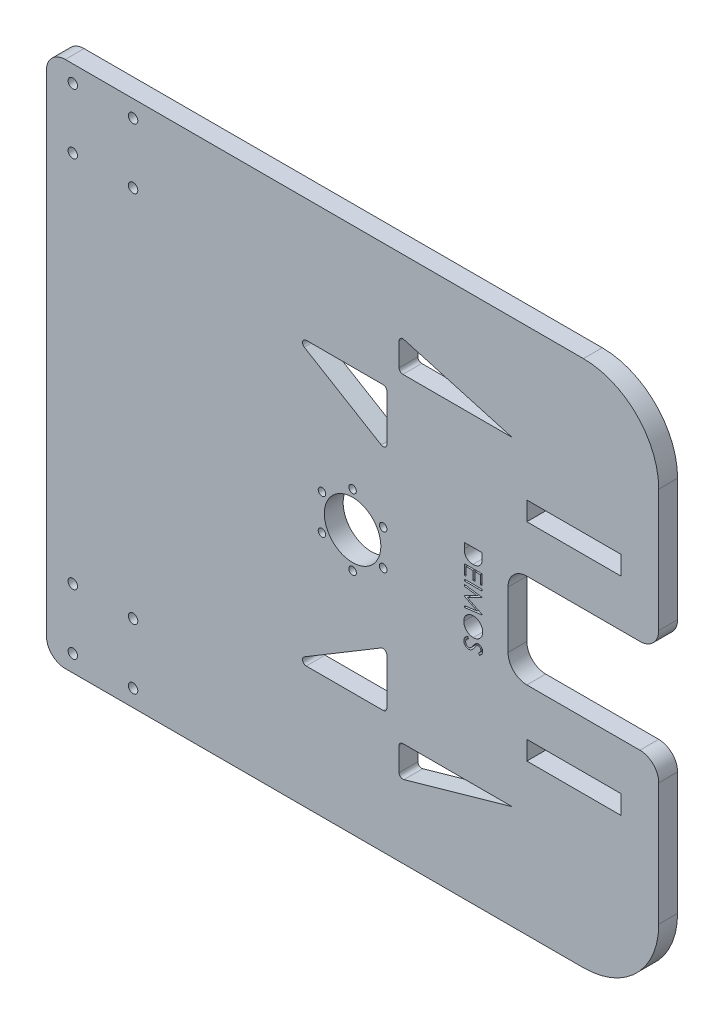
from build123d import *

# Parameters (mm, degrees)
SKETCH1_W           = 325
SKETCH1_H           = 280
SKETCH1_W_2         = 50
SKETCH1_H_2         = 10
SKETCH1_R           = 2
SKETCH1_R_2         = 15
BOSS_EXTRUDE1_DEPTH = 10
FILLET1_R           = 10
FILLET2_R           = 40
SKETCH4_W           = 80
SKETCH4_H           = 50
CUT_EXTRUDE5_DEPTH  = 10
FILLET4_R           = 10
FILLET5_R           = 2
SKETCH8_W           = 9.525
SKETCH8_H           = 0.854807693
CUT_EXTRUDE7_DEPTH  = 34
SKETCH9_R           = 2.5
CUT_EXTRUDE8_DEPTH  = 10


with BuildPart() as part:
    # Sketch1 → Boss-Extrude1 (new body)
    with BuildSketch(Plane.XY):
        with Locations((141.153836076, 0)):
            Rectangle(SKETCH1_W, SKETCH1_H)
        with Locations((258.653836076, -55)):
            Rectangle(SKETCH1_W_2, SKETCH1_H_2, mode=Mode.SUBTRACT)
        with Locations((258.653836076, 55)):
            Rectangle(SKETCH1_W_2, SKETCH1_H_2, mode=Mode.SUBTRACT)
        with Locations((157.391812397, 9.375)):
            Circle(SKETCH1_R, mode=Mode.SUBTRACT)
        with Locations((141.153836076, 18.75)):
            Circle(SKETCH1_R, mode=Mode.SUBTRACT)
        with Locations((124.915859755, -9.375)):
            Circle(SKETCH1_R, mode=Mode.SUBTRACT)
        with Locations((141.153836076, -18.75)):
            Circle(SKETCH1_R, mode=Mode.SUBTRACT)
        with Locations((157.391812397, -9.375)):
            Circle(SKETCH1_R, mode=Mode.SUBTRACT)
        with Locations((124.915859755, 9.375)):
            Circle(SKETCH1_R, mode=Mode.SUBTRACT)
        with Locations((141.153836076, 0)):
            Circle(SKETCH1_R_2, mode=Mode.SUBTRACT)
    extrude(amount=BOSS_EXTRUDE1_DEPTH)

    # Fillet1
    fillet1_edges = [part.edges().sort_by_distance(p)[0] for p in [
        (-21.346163924, -140, 5),
        (-21.346163924, 140, 5),
    ]]
    fillet(fillet1_edges, radius=FILLET1_R)

    # Fillet2
    fillet2_edges = [part.edges().sort_by_distance(p)[0] for p in [
        (303.653836076, 140, 5),
        (303.653836076, -140, 5),
    ]]
    fillet(fillet2_edges, radius=FILLET2_R)

    # Sketch4 → Cut-Extrude5 (cut)
    with BuildSketch(Plane.XY):
        with Locations((263.653836076, 0)):
            Rectangle(SKETCH4_W, SKETCH4_H)
        Polygon((109.344996748, -74.859442644), (159.344996748, -44.859442644), (159.344996748, -74.859442644), align=None)
        Polygon((165.847822117, -84.859442644), (225.847822117, -84.859442644), (165.847822117, -101.859442644), align=None)
        Polygon((159.344996748, 44.859442644), (159.344996748, 74.859442644), (109.344996748, 74.859442644), align=None)
        Polygon((225.847822117, 84.859442644), (165.847822117, 101.859442644), (165.847822117, 84.859442644), align=None)
    extrude(amount=CUT_EXTRUDE5_DEPTH, mode=Mode.SUBTRACT)

    # Fillet4
    fillet4_edges = [part.edges().sort_by_distance(p)[0] for p in [
        (303.653836076, 25, 5),
        (223.653836076, 25, 5),
        (223.653836076, -25, 5),
        (303.653836076, -25, 5),
    ]]
    fillet(fillet4_edges, radius=FILLET4_R)

    # Fillet5
    fillet5_edges = [part.edges().sort_by_distance(p)[0] for p in [
        (165.847822117, 84.859442644, 5),
        (165.847822117, 101.859442644, 5),
        (109.344996748, 74.859442644, 5),
        (159.344996748, 44.859442644, 5),
        (159.344996748, 74.859442644, 5),
        (159.344996748, -74.859442644, 5),
        (159.344996748, -44.859442644, 5),
        (109.344996748, -74.859442644, 5),
        (165.847822117, -101.859442644, 5),
        (165.847822117, -84.859442644, 5),
    ]]
    fillet(fillet5_edges, radius=FILLET5_R)

    # Sketch8 → Cut-Extrude7 (cut)
    with BuildSketch(Plane.XY.offset(10)):
        with BuildLine():
            Line((200.440471707, 23.934615385), (209.965471707, 23.934615385))
            Line((209.965471707, 23.934615385), (209.965471707, 22.011298077))
            add(Edge.make_bspline(
                [(209.965471707, 22.011298077), (209.964270566, 21.844014268), (209.961949968, 21.520822821), (209.947152078, 21.053796461), (209.921238906, 20.622294118), (209.882765221, 20.226560835), (209.836586017, 19.865960835), (209.777857599, 19.541071661), (209.708789002, 19.251366805), (209.649879683, 19.073196747), (209.622022187, 18.988942308)],
                knots=[0, 0, 0, 0, 0.000501851, 0.000969573, 0.001401619, 0.001798425, 0.002162189, 0.002491907, 0.002788546, 0.00305467, 0.00305467, 0.00305467, 0.00305467], degree=3))
            add(Edge.make_bspline(
                [(209.622022187, 18.988942308), (209.580028577, 18.878738837), (209.496993632, 18.660830945), (209.340358953, 18.350567689), (209.162883606, 18.05849316), (208.964348832, 17.783018556), (208.739076507, 17.530519725), (208.496845936, 17.290816903), (208.227758902, 17.074670535), (207.94095172, 16.873406548), (207.633514858, 16.697297269), (207.311687884, 16.54198934), (206.976072973, 16.409383485), (206.624227345, 16.305914399), (206.259528694, 16.22043131), (205.879216258, 16.163074194), (205.485507163, 16.124974184), (205.218328935, 16.121164022), (205.082764375, 16.119230769)],
                knots=[0, 0, 0, 0, 0.000353608, 0.000699197, 0.00104083, 0.00137821, 0.001716199, 0.002054872, 0.002399359, 0.002750285, 0.003105049, 0.003460915, 0.003821618, 0.004186221, 0.004560204, 0.004944486, 0.005339213, 0.00574579, 0.00574579, 0.00574579, 0.00574579], degree=3))
            add(Edge.make_bspline(
                [(205.082764375, 16.119230769), (204.965032402, 16.120943613), (204.733029254, 16.12431895), (204.391100832, 16.154590077), (204.059342581, 16.19867311), (203.739211546, 16.266610307), (203.42855118, 16.350088741), (203.12883677, 16.453126869), (202.839848629, 16.575237028), (202.56394077, 16.716909335), (202.301569629, 16.871821715), (202.057250154, 17.041674075), (201.82633571, 17.216719714), (201.619241743, 17.410455773), (201.424123862, 17.609531684), (201.251524644, 17.824504057), (201.093925803, 18.048369221), (200.952477694, 18.285439171), (200.829755793, 18.541396111), (200.724622122, 18.819733515), (200.638055098, 19.121942075), (200.565714706, 19.447558579), (200.50836302, 19.797221059), (200.469916507, 20.171250253), (200.443919613, 20.569077959), (200.441643325, 20.842252914), (200.440471707, 20.982857572)],
                knots=[0, 0, 0, 0, 0.000353119, 0.000695857, 0.001029112, 0.001356547, 0.00167685, 0.001993639, 0.002306565, 0.002617179, 0.002923468, 0.003219849, 0.003509528, 0.003791772, 0.004069759, 0.004345107, 0.004617718, 0.00489063, 0.005172254, 0.005468156, 0.005782145, 0.006114519, 0.006468353, 0.006844472, 0.007242122, 0.00766387, 0.00766387, 0.00766387, 0.00766387], degree=3))
            Line((200.440471707, 20.982857572), (200.440471707, 23.934615385))
        make_face()
        Polygon((209.965471707, 14.165384615), (209.965471707, 8.792307692), (208.98854863, 8.792307692), (208.98854863, 13.310576923), (206.057779399, 13.310576923), (206.057779399, 8.792307692), (205.080856322, 8.792307692), (205.080856322, 13.310576923), (201.417394783, 13.310576923), (201.417394783, 8.792307692), (200.440471707, 8.792307692), (200.440471707, 14.165384615), align=None)
        with Locations((205.202971707, 6.655288462)):
            Rectangle(SKETCH8_W, SKETCH8_H)
        Polygon((200.440471707, 4.640384615), (209.965471707, 3.382977764), (209.965471707, 3.26086238), (202.150087091, -0.671634615), (209.965471707, -4.592683293), (209.965471707, -4.714798678), (200.440471707, -5.983653846), (200.440471707, -5.128846154), (207.288473509, -4.212980769), (200.440471707, -0.776577524), (200.440471707, -0.58195613), (207.309462091, 2.869711538), (200.440471707, 3.779852764), align=None)
        with BuildLine():
            add(Edge.make_bspline(
                [(210.209702476, -12.394711538), (210.205235266, -12.571082134), (210.196461298, -12.917488535), (210.129299459, -13.426600011), (210.013104886, -13.912631959), (209.858364071, -14.379554575), (209.651903225, -14.821742714), (209.402495682, -15.242674716), (209.106594281, -15.641160444), (208.769164109, -16.013547296), (208.400688035, -16.353065594), (208.006324048, -16.649700392), (207.591472349, -16.900502873), (207.154689363, -17.106068081), (206.697897528, -17.267481758), (206.218499608, -17.378829993), (205.719645562, -17.449965839), (205.379393603, -17.458281542), (205.206787812, -17.4625)],
                knots=[0, 0, 0, 0, 0.000529026, 0.001039051, 0.001537035, 0.002026379, 0.002512127, 0.002998067, 0.00349188, 0.003998478, 0.00450354, 0.004992765, 0.00547641, 0.005955244, 0.006438614, 0.006926874, 0.007429591, 0.00794718, 0.00794718, 0.00794718, 0.00794718], degree=3))
            add(Edge.make_bspline(
                [(205.206787812, -17.4625), (205.035453471, -17.458282168), (204.697733636, -17.449968331), (204.202045381, -17.37874903), (203.725540779, -17.267069316), (203.269061561, -17.107565396), (202.831954548, -16.902987724), (202.416340309, -16.650490184), (202.019245707, -16.3558193), (201.648980849, -16.017474517), (201.308795571, -15.649086315), (201.011699586, -15.25361025), (200.75780913, -14.839166827), (200.553653877, -14.402647885), (200.391097833, -13.948919887), (200.28016285, -13.473824433), (200.208632608, -12.979481442), (200.20041682, -12.642376025), (200.196240937, -12.471033654)],
                knots=[0, 0, 0, 0, 0.000513777, 0.001012713, 0.001499117, 0.001980056, 0.002460617, 0.002944262, 0.003436543, 0.003941727, 0.004446788, 0.004938685, 0.005423319, 0.005902153, 0.006381925, 0.006866473, 0.00736352, 0.007877296, 0.007877296, 0.007877296, 0.007877296], degree=3))
            add(Edge.make_bspline(
                [(200.196240937, -12.471033654), (200.200456917, -12.298428563), (200.208767736, -11.958177981), (200.280026672, -11.458699888), (200.391415752, -10.978954853), (200.550753849, -10.520420003), (200.755904397, -10.082944867), (201.008003954, -9.666571754), (201.305068658, -9.270800327), (201.642962978, -8.899658018), (202.011528225, -8.56048412), (202.404404807, -8.262161092), (202.817856242, -8.011514942), (203.250178206, -7.806277791), (203.700253221, -7.643943019), (204.170912427, -7.533157505), (204.659518463, -7.461488875), (204.992193491, -7.453229375), (205.160994543, -7.449038462)],
                knots=[0, 0, 0, 0, 0.000517589, 0.001020306, 0.001510423, 0.001993164, 0.002473724, 0.00295737, 0.003450792, 0.003955976, 0.004461037, 0.004951411, 0.005433424, 0.005908808, 0.006384985, 0.006865822, 0.0073572, 0.007863352, 0.007863352, 0.007863352, 0.007863352], degree=3))
            add(Edge.make_bspline(
                [(205.160994543, -7.449038462), (205.274295396, -7.4504921), (205.499467761, -7.453381038), (205.833832819, -7.488212345), (206.162856664, -7.538653118), (206.485433279, -7.611320786), (206.801615339, -7.705055913), (207.110756234, -7.820568555), (207.415402377, -7.952946088), (207.709755812, -8.110559826), (207.994278547, -8.282521132), (208.265412862, -8.470027658), (208.518315566, -8.674386788), (208.7570504, -8.892679298), (208.977542704, -9.127926848), (209.184599716, -9.376588968), (209.37607806, -9.639966771), (209.547956163, -9.918476796), (209.705828289, -10.205018325), (209.837638522, -10.501670229), (209.954141092, -10.802173453), (210.046726087, -11.109174946), (210.120405778, -11.421964563), (210.170469266, -11.740933326), (210.205377968, -12.0657527), (210.208254771, -12.284586812), (210.209702476, -12.394711538)],
                knots=[0, 0, 0, 0, 0.000339767, 0.000675248, 0.001007452, 0.001337964, 0.001666382, 0.001996006, 0.002327486, 0.002662071, 0.00299683, 0.003324465, 0.003650167, 0.003971559, 0.004294156, 0.004616634, 0.00494181, 0.005270067, 0.005597924, 0.005922434, 0.006243129, 0.006564237, 0.00688359, 0.007206372, 0.007532359, 0.00786259, 0.00786259, 0.00786259, 0.00786259], degree=3))
        make_face()
        with BuildLine():
            Line((202.277926634, -18.439423077), (202.760664014, -19.244621394))
            add(Edge.make_bspline(
                [(202.760664014, -19.244621394), (202.635303081, -19.319510311), (202.39511637, -19.462994586), (202.070564132, -19.702347928), (201.794714262, -19.950359636), (201.569171495, -20.208866323), (201.39160131, -20.476290082), (201.265865237, -20.754376685), (201.187444618, -21.042189013), (201.177919382, -21.238060627), (201.173164014, -21.335847356)],
                knots=[0, 0, 0, 0, 0.00043788, 0.000838962, 0.00120771, 0.001548574, 0.001865575, 0.002167029, 0.002460907, 0.002753891, 0.002753891, 0.002753891, 0.002753891], degree=3))
            add(Edge.make_bspline(
                [(201.173164014, -21.335847356), (201.175489942, -21.419359463), (201.180101098, -21.584922413), (201.22440818, -21.828659534), (201.292476742, -22.065374772), (201.389961451, -22.290186495), (201.507901867, -22.500003146), (201.650365902, -22.683967297), (201.809831349, -22.843104563), (201.987864337, -22.972921455), (202.178671622, -23.07369915), (202.376278253, -23.146624678), (202.579815023, -23.193037391), (202.71780681, -23.198944798), (202.787376755, -23.201923077)],
                knots=[0, 0, 0, 0, 0.000250312, 0.000496243, 0.000740779, 0.000987811, 0.001229683, 0.001460959, 0.001683581, 0.001903405, 0.002119352, 0.00232883, 0.002533926, 0.002742463, 0.002742463, 0.002742463, 0.002742463], degree=3))
            add(Edge.make_bspline(
                [(202.787376755, -23.201923077), (202.866681496, -23.197910846), (203.027896445, -23.189754566), (203.265748358, -23.120816752), (203.501131709, -23.012369873), (203.646731582, -22.912322964), (203.722322668, -22.860381611)],
                knots=[0, 0, 0, 0, 0.000237528, 0.000482859, 0.000737261, 0.001011947, 0.001011947, 0.001011947, 0.001011947], degree=3))
            add(Edge.make_bspline(
                [(203.722322668, -22.860381611), (203.776990192, -22.817855884), (203.892094707, -22.728316379), (204.060566022, -22.572251465), (204.238590565, -22.393884351), (204.425445418, -22.192323333), (204.617718146, -21.963561796), (204.819416695, -21.71229708), (205.029934883, -21.437228491), (205.169148506, -21.243372581), (205.241132764, -21.143134014)],
                knots=[0, 0, 0, 0, 0.000207697, 0.000437315, 0.000688266, 0.000963713, 0.001261528, 0.001584548, 0.0019303, 0.002300507, 0.002300507, 0.002300507, 0.002300507], degree=3))
            add(Edge.make_bspline(
                [(205.241132764, -21.143134014), (205.31252833, -21.042933507), (205.449031214, -20.851357766), (205.651360372, -20.583236951), (205.837525552, -20.343799379), (206.004933543, -20.131824996), (206.160885832, -19.952797848), (206.297024248, -19.800173202), (206.420618429, -19.679581959), (206.500731761, -19.612475776), (206.536700673, -19.582346755)],
                knots=[0, 0, 0, 0, 0.000369089, 0.000705669, 0.001007564, 0.001279031, 0.001515791, 0.001719739, 0.001892457, 0.002033188, 0.002033188, 0.002033188, 0.002033188], degree=3))
            add(Edge.make_bspline(
                [(206.536700673, -19.582346755), (206.592764923, -19.540239328), (206.703022796, -19.457429423), (206.875356873, -19.348120508), (207.051768759, -19.255213215), (207.232732505, -19.182381439), (207.415707562, -19.121050729), (207.603081309, -19.079799504), (207.794012978, -19.053969345), (207.922501147, -19.051324153), (207.986820865, -19.05)],
                knots=[0, 0, 0, 0, 0.000210284, 0.000413552, 0.000611549, 0.000807494, 0.000998166, 0.001189809, 0.00138222, 0.001575084, 0.001575084, 0.001575084, 0.001575084], degree=3))
            add(Edge.make_bspline(
                [(207.986820865, -19.05), (208.087603189, -19.053536539), (208.287013686, -19.060534025), (208.578168028, -19.120196234), (208.856990978, -19.213265337), (209.117340916, -19.347870509), (209.358609011, -19.514292343), (209.577109082, -19.710976808), (209.762359255, -19.944496317), (209.922338884, -20.20214099), (210.048649491, -20.482333009), (210.144437234, -20.775414491), (210.197988448, -21.082670611), (210.205759434, -21.29113105), (210.209702476, -21.396905048)],
                knots=[0, 0, 0, 0, 0.000302076, 0.000597694, 0.000887926, 0.001181474, 0.001473631, 0.00176537, 0.002059785, 0.002364787, 0.002673031, 0.002979569, 0.003287618, 0.003604929, 0.003604929, 0.003604929, 0.003604929], degree=3))
            add(Edge.make_bspline(
                [(210.209702476, -21.396905048), (210.205903624, -21.509164652), (210.198370047, -21.731788871), (210.130522068, -22.059873542), (210.0209261, -22.376358734), (209.894698127, -22.631113806), (209.769191579, -22.830151271), (209.654829478, -22.981930148), (209.523182496, -23.135739135), (209.373886261, -23.292814468), (209.205574957, -23.450495902), (209.019400091, -23.611123991), (208.816499768, -23.775074471), (208.671653088, -23.880545776), (208.597397788, -23.934615385)],
                knots=[0, 0, 0, 0, 0.000336473, 0.000667265, 0.00100035, 0.001339114, 0.001517505, 0.001705639, 0.001908665, 0.002124604, 0.002355415, 0.002600249, 0.002862181, 0.003137708, 0.003137708, 0.003137708, 0.003137708], degree=3))
            Line((208.597397788, -23.934615385), (208.011625553, -23.161853966))
            add(Edge.make_bspline(
                [(208.011625553, -23.161853966), (208.071738348, -23.115192536), (208.187501536, -23.025333532), (208.349620594, -22.888909707), (208.497711231, -22.760325911), (208.626339652, -22.633642244), (208.742551271, -22.515549834), (208.842043366, -22.400930461), (208.925805628, -22.291438311), (209.015150812, -22.153404329), (209.104279244, -21.979544335), (209.178092803, -21.761515036), (209.224046886, -21.534289127), (209.229836564, -21.379950953), (209.232779399, -21.301502404)],
                knots=[0, 0, 0, 0, 0.000228266, 0.000439586, 0.000635596, 0.000816409, 0.000981033, 0.001132528, 0.001271436, 0.001394221, 0.001625473, 0.001855368, 0.002082883, 0.002318069, 0.002318069, 0.002318069, 0.002318069], degree=3))
            add(Edge.make_bspline(
                [(209.232779399, -21.301502404), (209.229481844, -21.203105011), (209.22312282, -21.013354907), (209.153672003, -20.743960051), (209.04431994, -20.501497297), (208.89106275, -20.29316496), (208.709486334, -20.119709329), (208.500538164, -19.994236616), (208.269808911, -19.918716526), (208.108859118, -19.909501008), (208.026889976, -19.904807692)],
                knots=[0, 0, 0, 0, 0.000294589, 0.000568087, 0.000828485, 0.001088009, 0.00133909, 0.001576985, 0.001813522, 0.002059009, 0.002059009, 0.002059009, 0.002059009], degree=3))
            add(Edge.make_bspline(
                [(208.026889976, -19.904807692), (207.975872177, -19.905927364), (207.873753155, -19.90816854), (207.722483533, -19.937317417), (207.57255668, -19.978649648), (207.423305932, -20.039141915), (207.27122005, -20.120622281), (207.116709648, -20.231411084), (206.95587371, -20.370012438), (206.851370443, -20.476391926), (206.796195865, -20.532557091)],
                knots=[0, 0, 0, 0, 0.000152835, 0.00030592, 0.000460554, 0.000618934, 0.000787967, 0.000976951, 0.001188047, 0.001424161, 0.001424161, 0.001424161, 0.001424161], degree=3))
            add(Edge.make_bspline(
                [(206.796195865, -20.532557091), (206.777589388, -20.553406969), (206.733384657, -20.602941506), (206.661015664, -20.693499561), (206.571745263, -20.813086748), (206.46128978, -20.95858031), (206.333160944, -21.132662915), (206.188997042, -21.335353707), (206.024118043, -21.564393308), (205.908845022, -21.726922236), (205.847893582, -21.812860577)],
                knots=[0, 0, 0, 0, 8.3824e-05, 0.000199147, 0.000347595, 0.000531532, 0.000747151, 0.000996018, 0.001277713, 0.001593788, 0.001593788, 0.001593788, 0.001593788], degree=3))
            add(Edge.make_bspline(
                [(205.847893582, -21.812860577), (205.772669596, -21.916236527), (205.627008774, -22.116409726), (205.408163244, -22.401227854), (205.19412896, -22.659474575), (204.986272758, -22.892056579), (204.786171305, -23.101271594), (204.591417221, -23.284798534), (204.40340577, -23.444507421), (204.162361832, -23.616445151), (203.866321881, -23.792134646), (203.503614674, -23.943014748), (203.139497545, -24.038151394), (202.894768083, -24.050592446), (202.774020384, -24.056730769)],
                knots=[0, 0, 0, 0, 0.000383538, 0.000742667, 0.001077361, 0.001389518, 0.001678297, 0.001945561, 0.002192062, 0.00241764, 0.002833245, 0.003221608, 0.003593213, 0.003955125, 0.003955125, 0.003955125, 0.003955125], degree=3))
            add(Edge.make_bspline(
                [(202.774020384, -24.056730769), (202.688627078, -24.054941421), (202.519498747, -24.051397473), (202.271144783, -24.010696862), (202.029978611, -23.95099033), (201.798762733, -23.861283074), (201.57440329, -23.750934675), (201.358966951, -23.614638564), (201.155415291, -23.450333689), (200.95951242, -23.267715476), (200.782555808, -23.064765944), (200.624287936, -22.850775085), (200.491818722, -22.624353646), (200.385180663, -22.386597533), (200.300456174, -22.138821965), (200.239557981, -21.880766184), (200.202096526, -21.611711583), (200.19821459, -21.428828661), (200.196240937, -21.335847356)],
                knots=[0, 0, 0, 0, 0.000255935, 0.0005069, 0.000753098, 0.001000094, 0.001249261, 0.001502285, 0.001763026, 0.002032986, 0.002304742, 0.002569597, 0.002830415, 0.003090022, 0.003350085, 0.00361481, 0.003884386, 0.004163197, 0.004163197, 0.004163197, 0.004163197], degree=3))
            add(Edge.make_bspline(
                [(200.196240937, -21.335847356), (200.197648022, -21.263908633), (200.20044447, -21.120937182), (200.224581178, -20.910032734), (200.259977953, -20.703001132), (200.313945216, -20.502441906), (200.380963984, -20.30585773), (200.463018769, -20.115000896), (200.56070082, -19.929407707), (200.67417193, -19.748861442), (200.804943386, -19.571660836), (200.956068854, -19.398714345), (201.12650448, -19.228043446), (201.317998122, -19.0627768), (201.528503866, -18.899868111), (201.759785543, -18.74234696), (202.010642557, -18.587005754), (202.18716784, -18.489536147), (202.277926634, -18.439423077)],
                knots=[0, 0, 0, 0, 0.000215745, 0.000428773, 0.000636128, 0.000845319, 0.001051079, 0.001258777, 0.001467881, 0.00167964, 0.001897927, 0.002127861, 0.002368018, 0.002620927, 0.002886174, 0.003166144, 0.003460022, 0.003771005, 0.003771005, 0.003771005, 0.003771005], degree=3))
        make_face()
    extrude(amount=-CUT_EXTRUDE7_DEPTH, mode=Mode.SUBTRACT)

    # Sketch9 → Cut-Extrude8 (cut)
    with BuildSketch(Plane.XY.offset(10)):
        with Locations((-7.346163924, -99)):
            Circle(SKETCH9_R)
        with Locations((24.653836076, -99)):
            Circle(SKETCH9_R)
        with Locations((-7.346163924, -131)):
            Circle(SKETCH9_R)
        with Locations((24.653836076, -131)):
            Circle(SKETCH9_R)
        with Locations((24.653836076, 131)):
            Circle(SKETCH9_R)
        with Locations((-7.346163924, 131)):
            Circle(SKETCH9_R)
        with Locations((24.653836076, 99)):
            Circle(SKETCH9_R)
        with Locations((-7.346163924, 99)):
            Circle(SKETCH9_R)
    extrude(amount=-CUT_EXTRUDE8_DEPTH, mode=Mode.SUBTRACT)


solid = part.part
